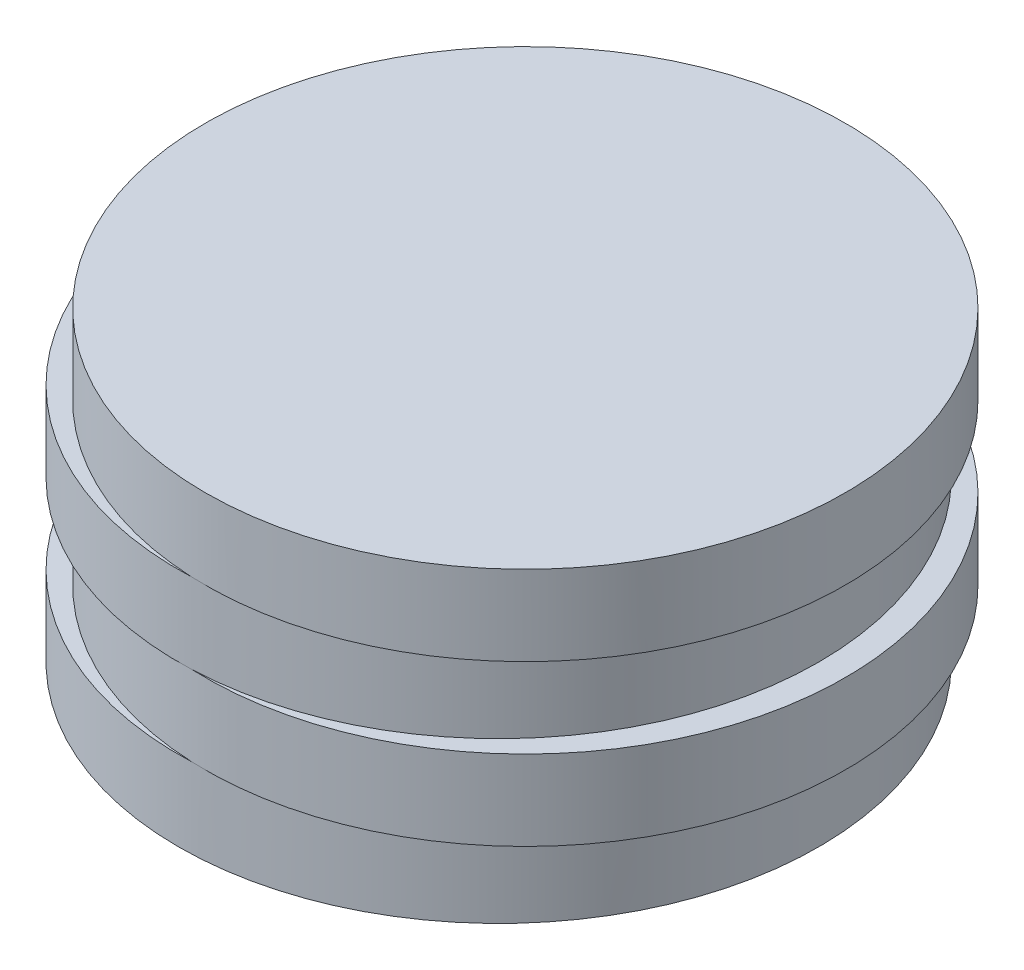
from build123d import *

# Parameters (mm, degrees)
SKETCH1_R           = 36
BOSS_EXTRUDE1_DEPTH = 9
SKETCH2_R           = 36
BOSS_EXTRUDE2_DEPTH = 9
SKETCH3_R           = 36
BOSS_EXTRUDE3_DEPTH = 9
SKETCH4_R           = 36
BOSS_EXTRUDE4_DEPTH = 9


with BuildPart() as part:
    # Sketch1 → Boss-Extrude1 (new body)
    with BuildSketch(Plane(origin=(0, 0, 0), x_dir=(1, 0, 0), z_dir=(0, 1, 0))):
        Circle(SKETCH1_R)
    extrude(amount=BOSS_EXTRUDE1_DEPTH)

    # Sketch2 → Boss-Extrude2 (add)
    with BuildSketch(Plane(origin=(0, 9, 0), x_dir=(1, 0, 0), z_dir=(0, 1, 0))):
        with Locations((3, 0)):
            Circle(SKETCH2_R)
    extrude(amount=BOSS_EXTRUDE2_DEPTH)

    # Sketch3 → Boss-Extrude3 (add)
    with BuildSketch(Plane(origin=(0, 18, 0), x_dir=(1, 0, 0), z_dir=(0, 1, 0))):
        Circle(SKETCH3_R)
    extrude(amount=BOSS_EXTRUDE3_DEPTH)

    # Sketch4 → Boss-Extrude4 (add)
    with BuildSketch(Plane(origin=(0, 27, 0), x_dir=(1, 0, 0), z_dir=(0, 1, 0))):
        with Locations((3, 0)):
            Circle(SKETCH4_R)
    extrude(amount=BOSS_EXTRUDE4_DEPTH)


solid = part.part
